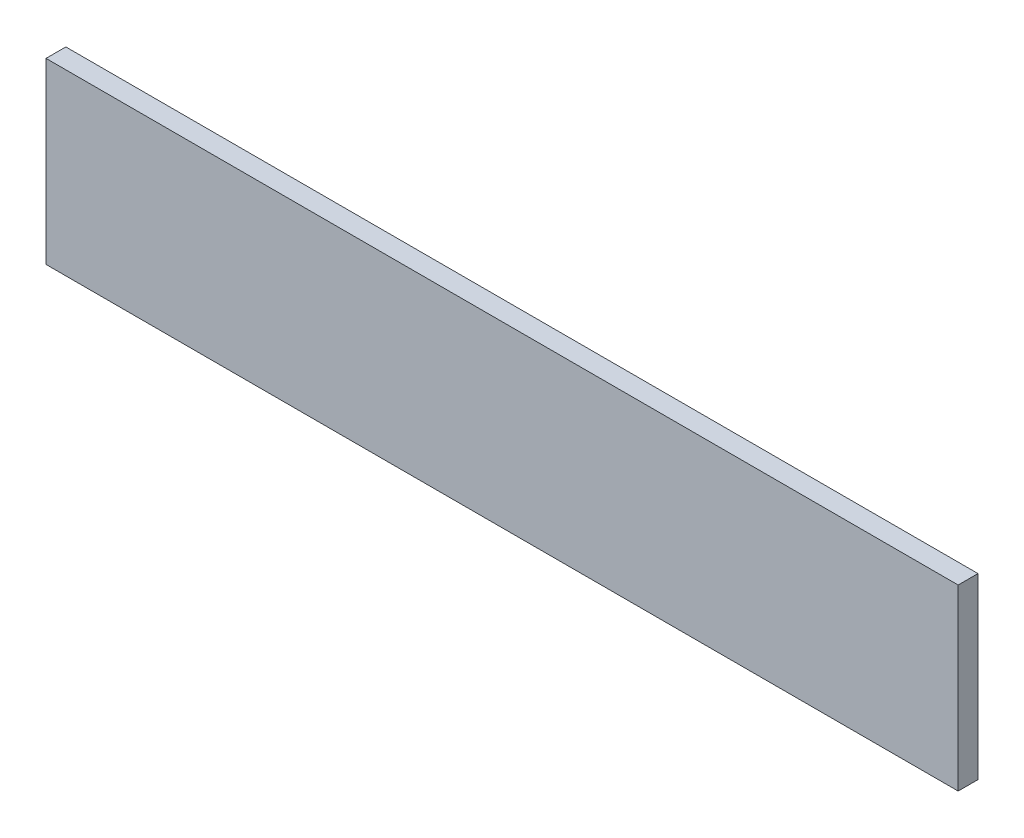
from build123d import *

# Parameters (mm, degrees)
SKETCH1_W           = 292.1
SKETCH1_H           = 57.15
BOSS_EXTRUDE1_DEPTH = 6.35


with BuildPart() as part:
    # Sketch1 → Boss-Extrude1 (new body)
    with BuildSketch(Plane.XY):
        with Locations((146.05, 28.575)):
            Rectangle(SKETCH1_W, SKETCH1_H)
    extrude(amount=BOSS_EXTRUDE1_DEPTH)


solid = part.part
